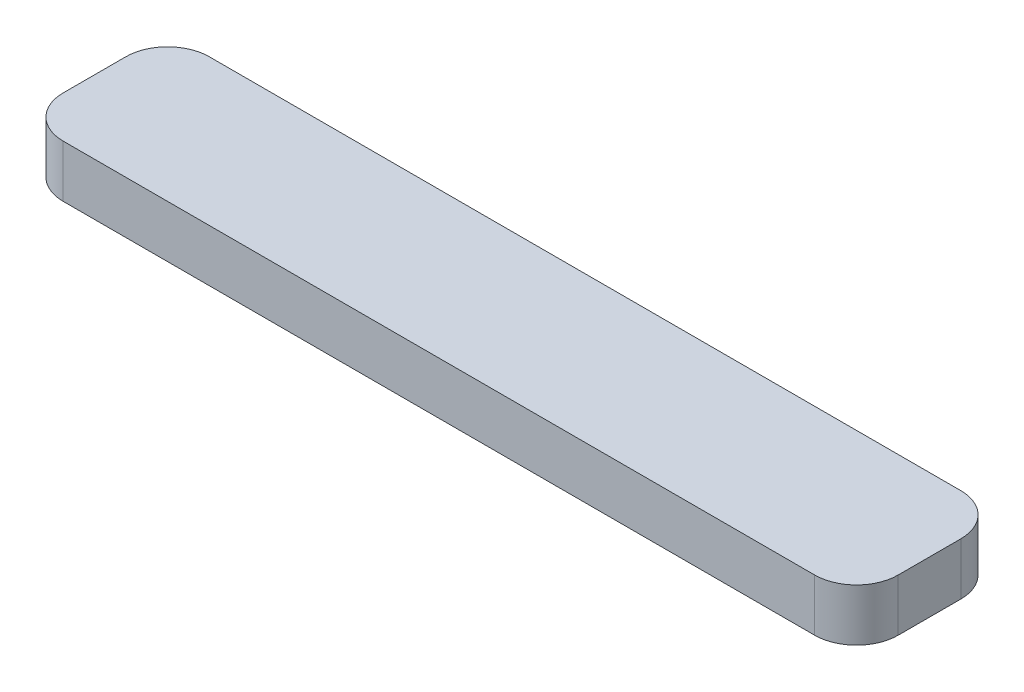
from build123d import *

# Parameters (mm, degrees)
SKETCH1_W           = 50.8
SKETCH1_H           = 8.89
BOSS_EXTRUDE1_DEPTH = 1.5875
FILLET1_R           = 2.54


with BuildPart() as part:
    # Sketch1 → Boss-Extrude1 (new body, symmetric)
    with BuildSketch(Plane(origin=(0, 0, 0), x_dir=(1, 0, 0), z_dir=(0, 1, 0))):
        Rectangle(SKETCH1_W, SKETCH1_H)
    extrude(amount=BOSS_EXTRUDE1_DEPTH, both=True)

    # Fillet1
    fillet1_edges = [part.edges().sort_by_distance(p)[0] for p in [
        (-25.4, 0, -4.445),
        (25.4, 0, -4.445),
        (25.4, 0, 4.445),
        (-25.4, 0, 4.445),
    ]]
    fillet(fillet1_edges, radius=FILLET1_R)


solid = part.part
